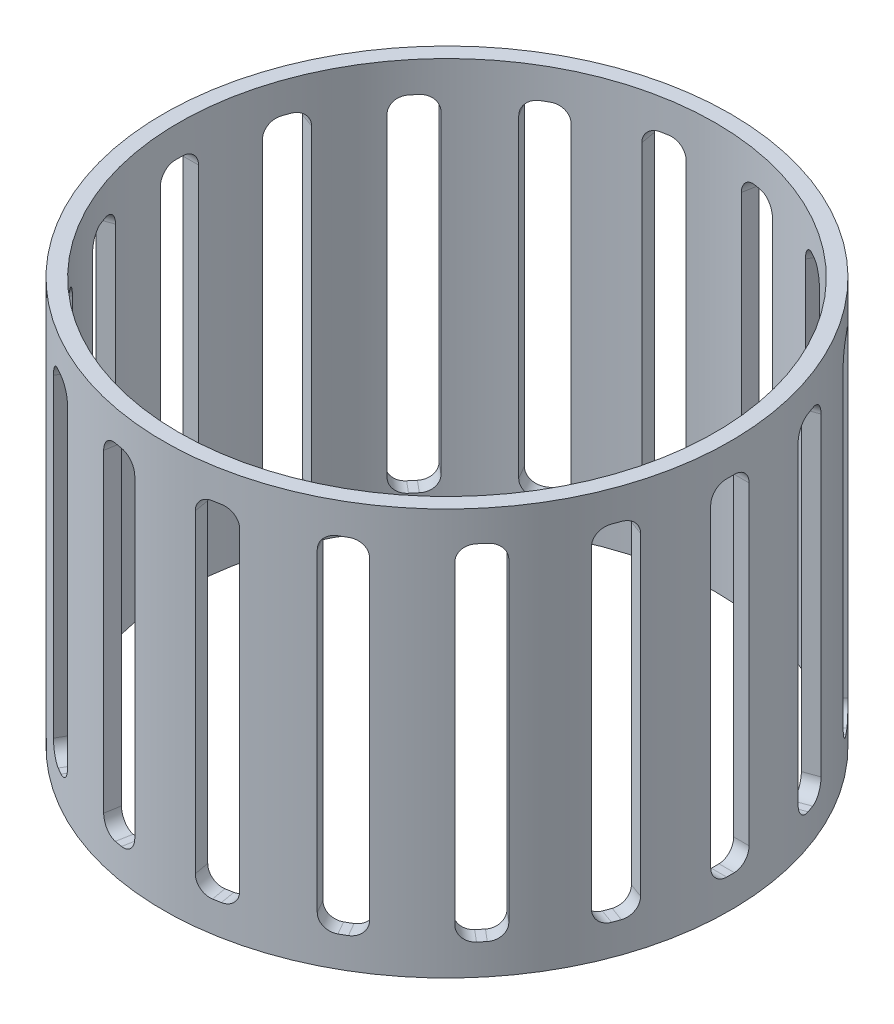
from build123d import *

# Parameters (mm, degrees)
SZKIC1_W                        = 2
SZKIC1_H                        = 53
WYTNIJ_WYCI_GNI_CIE1_START      = -37
SZKIC2_W                        = 5
SZKIC2_H                        = 45
WYTNIJ_WYCI_GNI_CIE1_DEPTH      = 2.0894
ZAOKR_GLENIE1_R                 = 2
SZYK_KO_OWY1_COUNT              = 18
ZAOKR_GLENIE1_OF_SZYK_KO_OWY1_R = 2


with BuildPart() as part:
    # Szkic1 → Obrót1 (revolve)
    with BuildSketch(Plane.XY):
        with Locations((-36, 0)):
            Rectangle(SZKIC1_W, SZKIC1_H)
    revolve(axis=Axis((0, -11.541666667, 0), (0, 1, 0)))

    # Szkic2 → Wytnij-wyciągnięcie1 (cut)
    with BuildSketch(Plane(origin=(0, 0, 0), x_dir=(0, 0, -1), z_dir=(1, 0, 0)).offset(WYTNIJ_WYCI_GNI_CIE1_START)):
        Rectangle(SZKIC2_W, SZKIC2_H)
    wytnij_wyci_gni_cie1 = extrude(amount=WYTNIJ_WYCI_GNI_CIE1_DEPTH, mode=Mode.SUBTRACT)

    # Zaokrąglenie1
    zaokr_glenie1_edges = [part.edges().sort_by_distance(p)[0] for p in [
        (-35.913021961, -22.5, -2.5),
        (-35.913021961, -22.5, 2.5),
        (-35.913021961, 22.5, 2.5),
        (-35.913021961, 22.5, -2.5),
    ]]
    fillet(zaokr_glenie1_edges, radius=ZAOKR_GLENIE1_R)

    # Szyk kołowy1: Wytnij-wyciągnięcie1 ×18 about axis
    szyk_ko_owy1_axis = Axis((0, 0, 0), (0, 1, 0))
    for i in range(1, SZYK_KO_OWY1_COUNT):
        add(wytnij_wyci_gni_cie1.rotate(szyk_ko_owy1_axis, i * 360 / SZYK_KO_OWY1_COUNT), mode=Mode.SUBTRACT)

    # Zaokrąglenie1 of Szyk kołowy1
    zaokr_glenie1_of_szyk_ko_owy1_edges = [part.edges().sort_by_distance(p)[0] for p in [
        (-34.602252085, -22.5, 9.933745366),
        (-32.892151369, -22.5, 14.63220847),
        (-32.892151369, 22.5, 14.63220847),
        (-34.602252085, 22.5, 9.933745366),
        (-29.117939933, -22.5, 21.169334435),
        (-25.904001885, -22.5, 24.999556651),
        (-25.904001885, 22.5, 24.999556651),
        (-29.117939933, 22.5, 21.169334435),
        (-20.12157449, -22.5, 29.851589345),
        (-15.791447471, -22.5, 32.351589345),
        (-15.791447471, 22.5, 32.351589345),
        (-20.12157449, 22.5, 29.851589345),
        (-8.698250201, -22.5, 34.933302017),
        (-3.774211436, -22.5, 35.801542906),
        (-3.774211436, 22.5, 35.801542906),
        (-8.698250201, 22.5, 34.933302017),
        (3.774211436, -22.5, 35.801542906),
        (8.698250201, -22.5, 34.933302017),
        (8.698250201, 22.5, 34.933302017),
        (3.774211436, 22.5, 35.801542906),
        (15.791447471, -22.5, 32.351589345),
        (20.12157449, -22.5, 29.851589345),
        (20.12157449, 22.5, 29.851589345),
        (15.791447471, 22.5, 32.351589345),
        (25.904001885, -22.5, 24.999556651),
        (29.117939933, -22.5, 21.169334435),
        (29.117939933, 22.5, 21.169334435),
        (25.904001885, 22.5, 24.999556651),
        (32.892151369, -22.5, 14.63220847),
        (34.602252085, -22.5, 9.933745366),
        (34.602252085, 22.5, 9.933745366),
        (32.892151369, 22.5, 14.63220847),
        (35.913021961, -22.5, 2.5),
        (35.913021961, -22.5, -2.5),
        (35.913021961, 22.5, -2.5),
        (35.913021961, 22.5, 2.5),
        (34.602252085, -22.5, -9.933745366),
        (32.892151369, -22.5, -14.63220847),
        (32.892151369, 22.5, -14.63220847),
        (34.602252085, 22.5, -9.933745366),
        (29.117939933, -22.5, -21.169334435),
        (25.904001885, -22.5, -24.999556651),
        (25.904001885, 22.5, -24.999556651),
        (29.117939933, 22.5, -21.169334435),
        (20.12157449, -22.5, -29.851589345),
        (15.791447471, -22.5, -32.351589345),
        (15.791447471, 22.5, -32.351589345),
        (20.12157449, 22.5, -29.851589345),
        (8.698250201, -22.5, -34.933302017),
        (3.774211436, -22.5, -35.801542906),
        (3.774211436, 22.5, -35.801542906),
        (8.698250201, 22.5, -34.933302017),
        (-3.774211436, -22.5, -35.801542906),
        (-8.698250201, -22.5, -34.933302017),
        (-8.698250201, 22.5, -34.933302017),
        (-3.774211436, 22.5, -35.801542906),
        (-15.791447471, -22.5, -32.351589345),
        (-20.12157449, -22.5, -29.851589345),
        (-20.12157449, 22.5, -29.851589345),
        (-15.791447471, 22.5, -32.351589345),
        (-25.904001885, -22.5, -24.999556651),
        (-29.117939933, -22.5, -21.169334435),
        (-29.117939933, 22.5, -21.169334435),
        (-25.904001885, 22.5, -24.999556651),
        (-32.892151369, -22.5, -14.63220847),
        (-34.602252085, -22.5, -9.933745366),
        (-34.602252085, 22.5, -9.933745366),
        (-32.892151369, 22.5, -14.63220847),
    ]]
    fillet(zaokr_glenie1_of_szyk_ko_owy1_edges, radius=ZAOKR_GLENIE1_OF_SZYK_KO_OWY1_R)


solid = part.part
